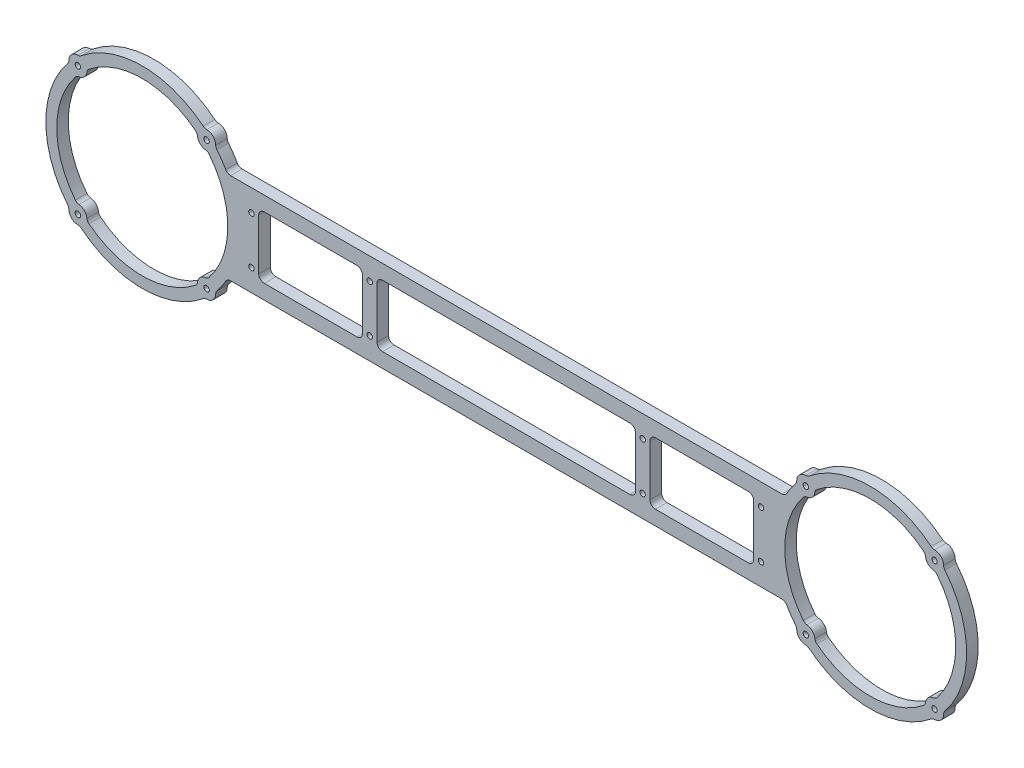
from build123d import *

# Parameters (mm, degrees)
SKETCH1_R           = 1.5
BOSS_EXTRUDE1_DEPTH = 6.35


with BuildPart() as part:
    # Sketch1 → Boss-Extrude1 (new body)
    with BuildSketch(Plane(origin=(0, 0, 0), x_dir=(-1, 0, 0), z_dir=(0, 0, -1))):
        with BuildLine():
            Line((151.502577388, 25), (-151.502577388, 25))
            ThreePointArc((-151.502577388, 25), (-153.002577388, 25.401923789), (-154.1006536, 26.5))
            ThreePointArc((-154.1006536, 26.5), (-156.391647728, 30.121613703), (-158.967745468, 33.54629768))
            ThreePointArc((-158.967745468, 33.54629768), (-159.465036881, 34.421268405), (-159.644975992, 35.411467596))
            ThreePointArc((-159.644975992, 35.411467596), (-161.109127035, 38.890872965), (-164.588532404, 40.355024008))
            ThreePointArc((-164.588532404, 40.355024008), (-165.578731594, 40.534963119), (-166.45370232, 41.032254532))
            ThreePointArc((-166.45370232, 41.032254532), (-200, 53), (-233.54629768, 41.032254532))
            ThreePointArc((-233.54629768, 41.032254532), (-234.421268405, 40.534963119), (-235.411467596, 40.355024008))
            ThreePointArc((-235.411467596, 40.355024008), (-238.890872965, 38.890872965), (-240.355024008, 35.411467596))
            ThreePointArc((-240.355024008, 35.411467596), (-240.534963119, 34.421268406), (-241.032254532, 33.54629768))
            ThreePointArc((-241.032254532, 33.54629768), (-253, 0), (-241.032254532, -33.54629768))
            ThreePointArc((-241.032254532, -33.54629768), (-240.534963119, -34.421268405), (-240.355024008, -35.411467596))
            ThreePointArc((-240.355024008, -35.411467596), (-238.890872965, -38.890872965), (-235.411467596, -40.355024008))
            ThreePointArc((-235.411467596, -40.355024008), (-234.421268406, -40.534963119), (-233.54629768, -41.032254532))
            ThreePointArc((-233.54629768, -41.032254532), (-200, -53), (-166.45370232, -41.032254532))
            ThreePointArc((-166.45370232, -41.032254532), (-165.578731595, -40.534963119), (-164.588532404, -40.355024008))
            ThreePointArc((-164.588532404, -40.355024008), (-161.109127035, -38.890872965), (-159.644975992, -35.411467596))
            ThreePointArc((-159.644975992, -35.411467596), (-159.465036881, -34.421268405), (-158.967745468, -33.54629768))
            ThreePointArc((-158.967745468, -33.54629768), (-156.391647728, -30.121613703), (-154.1006536, -26.5))
            ThreePointArc((-154.1006536, -26.5), (-153.002577388, -25.401923789), (-151.502577388, -25))
            Line((-151.502577388, -25), (151.502577388, -25))
            ThreePointArc((151.502577388, -25), (153.002577388, -25.401923789), (154.100653599, -26.5))
            ThreePointArc((154.100653599, -26.5), (156.391647728, -30.121613703), (158.967745468, -33.54629768))
            ThreePointArc((158.967745468, -33.54629768), (159.465036881, -34.421268405), (159.644975992, -35.411467596))
            ThreePointArc((159.644975992, -35.411467596), (161.109127035, -38.890872965), (164.588532404, -40.355024008))
            ThreePointArc((164.588532404, -40.355024008), (165.578731594, -40.534963119), (166.45370232, -41.032254532))
            ThreePointArc((166.45370232, -41.032254532), (200, -53), (233.546297679, -41.032254532))
            ThreePointArc((233.546297679, -41.032254532), (234.421268405, -40.534963119), (235.411467596, -40.355024008))
            ThreePointArc((235.411467596, -40.355024008), (238.890872965, -38.890872965), (240.355024008, -35.411467596))
            ThreePointArc((240.355024008, -35.411467596), (240.534963119, -34.421268405), (241.032254532, -33.546297679))
            ThreePointArc((241.032254532, -33.546297679), (253, 0), (241.032254532, 33.54629768))
            ThreePointArc((241.032254532, 33.54629768), (240.534963119, 34.421268406), (240.355024008, 35.411467596))
            ThreePointArc((240.355024008, 35.411467596), (238.890872965, 38.890872965), (235.411467596, 40.355024008))
            ThreePointArc((235.411467596, 40.355024008), (234.421268405, 40.534963119), (233.546297679, 41.032254532))
            ThreePointArc((233.546297679, 41.032254532), (200, 53), (166.45370232, 41.032254532))
            ThreePointArc((166.45370232, 41.032254532), (165.578731594, 40.534963119), (164.588532404, 40.355024008))
            ThreePointArc((164.588532404, 40.355024008), (161.109127035, 38.890872965), (159.644975992, 35.411467596))
            ThreePointArc((159.644975992, 35.411467596), (159.465036881, 34.421268406), (158.967745468, 33.54629768))
            ThreePointArc((158.967745468, 33.54629768), (156.391647727, 30.121613703), (154.100653599, 26.5))
            ThreePointArc((154.100653599, 26.5), (153.002577388, 25.401923789), (151.502577388, 25))
        make_face()
        with Locations((-235.355339059, -35.355339059)):
            Circle(SKETCH1_R, mode=Mode.SUBTRACT)
        with Locations((-235.355339059, 35.355339059)):
            Circle(SKETCH1_R, mode=Mode.SUBTRACT)
        with Locations((-164.644660941, -35.355339059)):
            Circle(SKETCH1_R, mode=Mode.SUBTRACT)
        with Locations((-164.644660941, 35.355339059)):
            Circle(SKETCH1_R, mode=Mode.SUBTRACT)
        with Locations((235.355339059, -35.355339059)):
            Circle(SKETCH1_R, mode=Mode.SUBTRACT)
        with Locations((235.355339059, 35.355339059)):
            Circle(SKETCH1_R, mode=Mode.SUBTRACT)
        with Locations((164.644660941, -35.355339059)):
            Circle(SKETCH1_R, mode=Mode.SUBTRACT)
        with Locations((164.644660941, 35.355339059)):
            Circle(SKETCH1_R, mode=Mode.SUBTRACT)
        with Locations((75, 13)):
            Circle(SKETCH1_R, mode=Mode.SUBTRACT)
        with Locations((75, -13)):
            Circle(SKETCH1_R, mode=Mode.SUBTRACT)
        with Locations((-75, -13)):
            Circle(SKETCH1_R, mode=Mode.SUBTRACT)
        with Locations((-75, 13)):
            Circle(SKETCH1_R, mode=Mode.SUBTRACT)
        with Locations((140, 13)):
            Circle(SKETCH1_R, mode=Mode.SUBTRACT)
        with Locations((140, -13)):
            Circle(SKETCH1_R, mode=Mode.SUBTRACT)
        with Locations((-140, -13)):
            Circle(SKETCH1_R, mode=Mode.SUBTRACT)
        with Locations((-140, 13)):
            Circle(SKETCH1_R, mode=Mode.SUBTRACT)
        with BuildLine():
            Line((136, 14), (136, -14))
            ThreePointArc((136, -14), (135.121320344, -16.121320344), (133, -17))
            Line((133, -17), (82, -17))
            ThreePointArc((82, -17), (79.878679656, -16.121320344), (79, -14))
            Line((79, -14), (79, 14))
            ThreePointArc((79, 14), (79.878679656, 16.121320344), (82, 17))
            Line((82, 17), (133, 17))
            ThreePointArc((133, 17), (135.121320344, 16.121320344), (136, 14))
        make_face(mode=Mode.SUBTRACT)
        with BuildLine():
            Line((71, 14), (71, -14))
            ThreePointArc((71, -14), (70.121320344, -16.121320344), (68, -17))
            Line((68, -17), (-68, -17))
            ThreePointArc((-68, -17), (-70.121320344, -16.121320344), (-71, -14))
            Line((-71, -14), (-71, 14))
            ThreePointArc((-71, 14), (-70.121320344, 16.121320344), (-68, 17))
            Line((-68, 17), (68, 17))
            ThreePointArc((68, 17), (70.121320344, 16.121320344), (71, 14))
        make_face(mode=Mode.SUBTRACT)
        with BuildLine():
            Line((-136, -14), (-136, 14))
            ThreePointArc((-136, 14), (-135.121320344, 16.121320344), (-133, 17))
            Line((-133, 17), (-82, 17))
            ThreePointArc((-82, 17), (-79.878679656, 16.121320344), (-79, 14))
            Line((-79, 14), (-79, -14))
            ThreePointArc((-79, -14), (-79.878679656, -16.121320344), (-82, -17))
            Line((-82, -17), (-133, -17))
            ThreePointArc((-133, -17), (-135.121320344, -16.121320344), (-136, -14))
        make_face(mode=Mode.SUBTRACT)
        with BuildLine():
            ThreePointArc((-163.234137081, -29.279196093), (-164.12216388, -30.031781356), (-165.229806783, -30.389696669))
            ThreePointArc((-165.229806783, -30.389696669), (-168.180194847, -31.819805153), (-169.610303331, -34.770193217))
            ThreePointArc((-169.610303331, -34.770193217), (-169.968218644, -35.87783612), (-170.720803907, -36.765862919))
            ThreePointArc((-170.720803907, -36.765862919), (-200, -47), (-229.279196093, -36.765862918))
            ThreePointArc((-229.279196093, -36.765862918), (-230.031781356, -35.87783612), (-230.38969667, -34.770193216))
            ThreePointArc((-230.38969667, -34.770193216), (-231.819805153, -31.819805153), (-234.770193217, -30.38969667))
            ThreePointArc((-234.770193217, -30.38969667), (-235.87783612, -30.031781356), (-236.765862918, -29.279196093))
            ThreePointArc((-236.765862918, -29.279196093), (-247, 0), (-236.765862918, 29.279196093))
            ThreePointArc((-236.765862918, 29.279196093), (-235.87783612, 30.031781356), (-234.770193216, 30.38969667))
            ThreePointArc((-234.770193216, 30.38969667), (-231.819805153, 31.819805153), (-230.38969667, 34.770193217))
            ThreePointArc((-230.38969667, 34.770193217), (-230.031781356, 35.87783612), (-229.279196093, 36.765862918))
            ThreePointArc((-229.279196093, 36.765862918), (-200, 47), (-170.720803907, 36.765862918))
            ThreePointArc((-170.720803907, 36.765862918), (-169.968218644, 35.87783612), (-169.61030333, 34.770193216))
            ThreePointArc((-169.61030333, 34.770193216), (-168.180194847, 31.819805153), (-165.229806783, 30.38969667))
            ThreePointArc((-165.229806783, 30.38969667), (-164.12216388, 30.031781356), (-163.234137082, 29.279196093))
            ThreePointArc((-163.234137082, 29.279196093), (-153, 0), (-163.234137081, -29.279196093))
        make_face(mode=Mode.SUBTRACT)
        with BuildLine():
            ThreePointArc((165.229806783, -30.389696669), (164.12216388, -30.031781356), (163.234137081, -29.279196093))
            ThreePointArc((163.234137081, -29.279196093), (153, 0), (163.234137082, 29.279196093))
            ThreePointArc((163.234137082, 29.279196093), (164.12216388, 30.031781357), (165.229806783, 30.38969667))
            ThreePointArc((165.229806783, 30.38969667), (168.180194847, 31.819805154), (169.61030333, 34.770193217))
            ThreePointArc((169.61030333, 34.770193217), (169.968218643, 35.87783612), (170.720803907, 36.765862918))
            ThreePointArc((170.720803907, 36.765862918), (200, 47), (229.279196093, 36.765862919))
            ThreePointArc((229.279196093, 36.765862919), (230.031781356, 35.87783612), (230.38969667, 34.770193217))
            ThreePointArc((230.38969667, 34.770193217), (231.819805153, 31.819805154), (234.770193216, 30.38969667))
            ThreePointArc((234.770193216, 30.38969667), (235.87783612, 30.031781357), (236.765862918, 29.279196093))
            ThreePointArc((236.765862918, 29.279196093), (247, 0), (236.765862918, -29.279196093))
            ThreePointArc((236.765862918, -29.279196093), (235.87783612, -30.031781356), (234.770193216, -30.389696669))
            ThreePointArc((234.770193216, -30.389696669), (231.819805153, -31.819805153), (230.389696669, -34.770193216))
            ThreePointArc((230.389696669, -34.770193216), (230.031781356, -35.87783612), (229.279196093, -36.765862918))
            ThreePointArc((229.279196093, -36.765862918), (200, -47), (170.720803907, -36.765862919))
            ThreePointArc((170.720803907, -36.765862919), (169.968218644, -35.87783612), (169.610303331, -34.770193216))
            ThreePointArc((169.610303331, -34.770193216), (168.180194847, -31.819805153), (165.229806783, -30.389696669))
        make_face(mode=Mode.SUBTRACT)
    extrude(amount=-BOSS_EXTRUDE1_DEPTH)


solid = part.part
